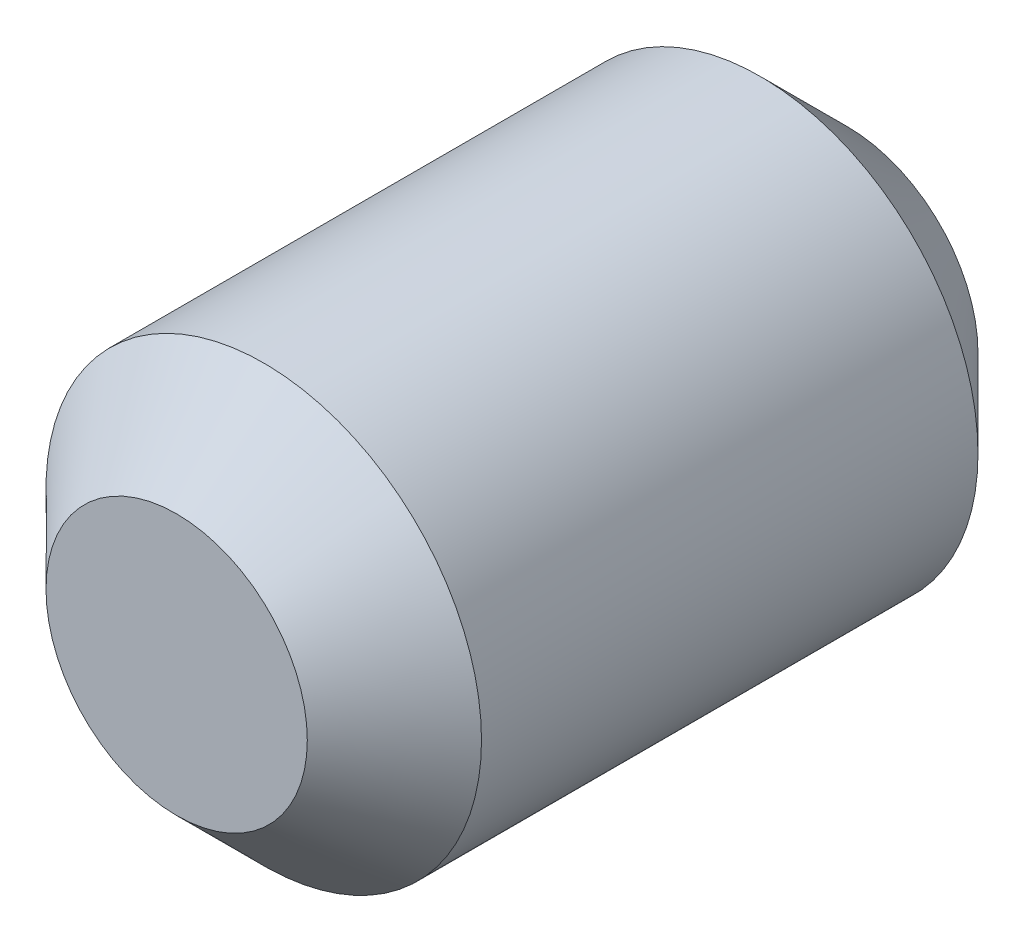
from build123d import *

# Parameters (mm, degrees)
ESQUISSE1_R          = 2.5
BASE_EXTRUSION_DEPTH = 3.85
CHANFREIN1_SIZE      = 1


with BuildPart() as part:
    # Esquisse1 → Base-Extrusion (new body, symmetric)
    with BuildSketch(Plane.XY):
        Circle(ESQUISSE1_R)
    extrude(amount=BASE_EXTRUSION_DEPTH, both=True)

    # Chanfrein1
    chanfrein1_edges = [part.edges().sort_by_distance(p)[0] for p in [
        (-2.5, 0, -3.85),
        (-2.5, 0, 3.85),
    ]]
    chamfer(chanfrein1_edges, length=CHANFREIN1_SIZE)


solid = part.part
